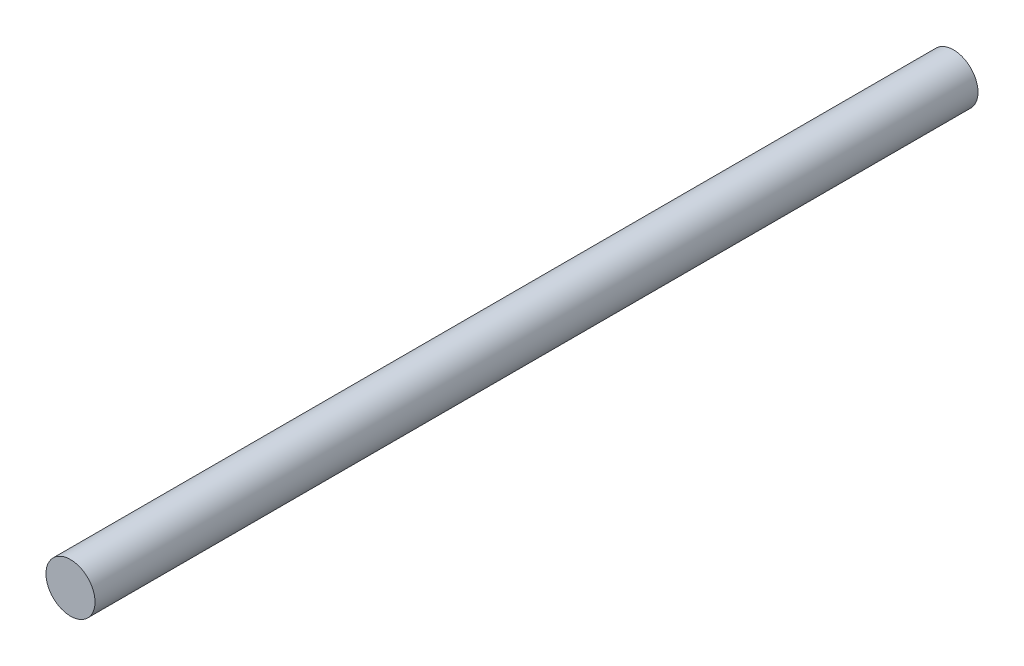
from build123d import *

# Parameters (mm, degrees)
SKETCH1_R           = 3.175
BOSS_EXTRUDE1_DEPTH = 57.15


with BuildPart() as part:
    # Sketch1 → Boss-Extrude1 (new body, symmetric)
    with BuildSketch(Plane.XY):
        Circle(SKETCH1_R)
    extrude(amount=BOSS_EXTRUDE1_DEPTH, both=True)


solid = part.part
